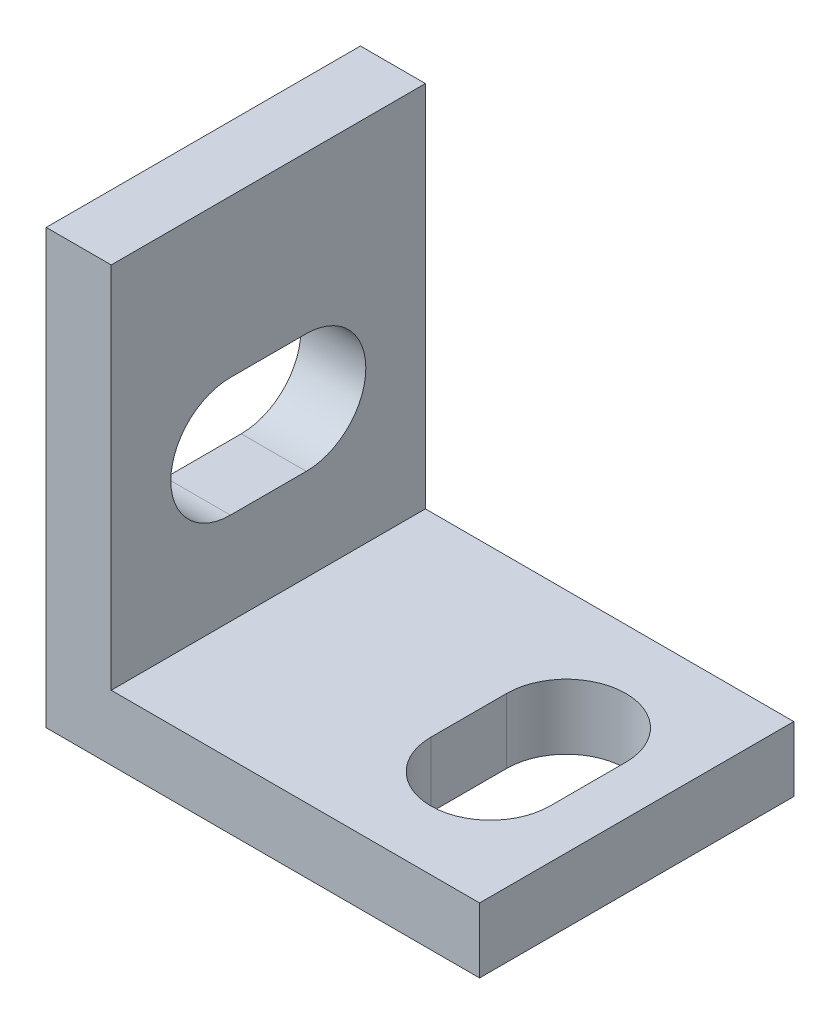
from build123d import *

# Parameters (mm, degrees)
EXTRUDE_THIN1_DEPTH = 14.5
CUT_EXTRUDE1_DEPTH  = 4
CUT_EXTRUDE2_DEPTH  = 4


with BuildPart() as part:
    # Sketch1 → Extrude-Thin1 (new body)
    with BuildSketch(Plane.XY):
        Polygon((0, 20), (0, 0), (20, 0), (20, 3), (3, 3), (3, 20), align=None)
    extrude(amount=EXTRUDE_THIN1_DEPTH)

    # Sketch2 → Cut-Extrude1 (cut, through all)
    with BuildSketch(Plane(origin=(3, 0, 0), x_dir=(0, 0, -1), z_dir=(1, 0, 0))):
        with BuildLine():
            Line((-5.5, 7.25), (-9, 7.25))
            ThreePointArc((-9, 7.25), (-11.75, 10), (-9, 12.75))
            Line((-9, 12.75), (-5.5, 12.75))
            ThreePointArc((-5.5, 12.75), (-2.75, 10), (-5.5, 7.25))
        make_face()
    extrude(amount=-CUT_EXTRUDE1_DEPTH, mode=Mode.SUBTRACT)

    # Sketch3 → Cut-Extrude2 (cut, through all)
    with BuildSketch(Plane(origin=(0, 3, 0), x_dir=(1, 0, 0), z_dir=(0, 1, 0))):
        with BuildLine():
            Line((12.25, -9), (12.25, -5.5))
            ThreePointArc((12.25, -5.5), (15, -2.75), (17.75, -5.5))
            Line((17.75, -5.5), (17.75, -9))
            ThreePointArc((17.75, -9), (15, -11.75), (12.25, -9))
        make_face()
    extrude(amount=-CUT_EXTRUDE2_DEPTH, mode=Mode.SUBTRACT)


solid = part.part
